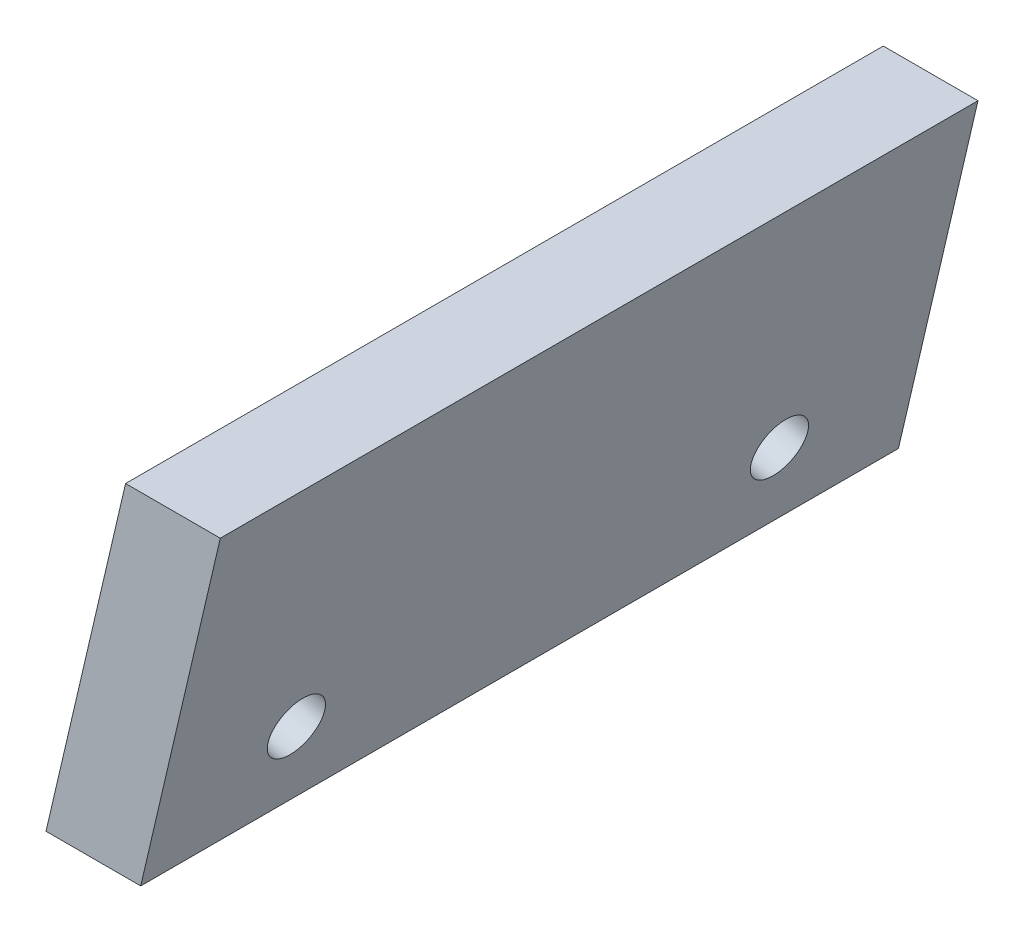
from build123d import *

# Parameters (mm, degrees)
BOSS_EXTRUDE2_DEPTH = 20
SKETCH4_R           = 0.75
CUT_EXTRUDE1_DEPTH  = 5.479855617


with BuildPart() as part:
    # Sketch2 → Boss-Extrude2 (new body)
    with BuildSketch(Plane.XY):
        Polygon((0, 0), (2.5, 0), (4.600215416, 9), (2.100215416, 9), align=None)
    extrude(amount=BOSS_EXTRUDE2_DEPTH)

    # Sketch4 → Cut-Extrude1 (cut, through all)
    with BuildSketch(Plane(origin=(0, 0, 0), x_dir=(0, 0, 1), z_dir=(-0.973836052, 0.227251721, 0))):
        with Locations((3.625, 2.7)):
            Circle(SKETCH4_R)
        with Locations((16.375, 2.7)):
            Circle(SKETCH4_R)
    extrude(amount=-CUT_EXTRUDE1_DEPTH, mode=Mode.SUBTRACT)


solid = part.part
